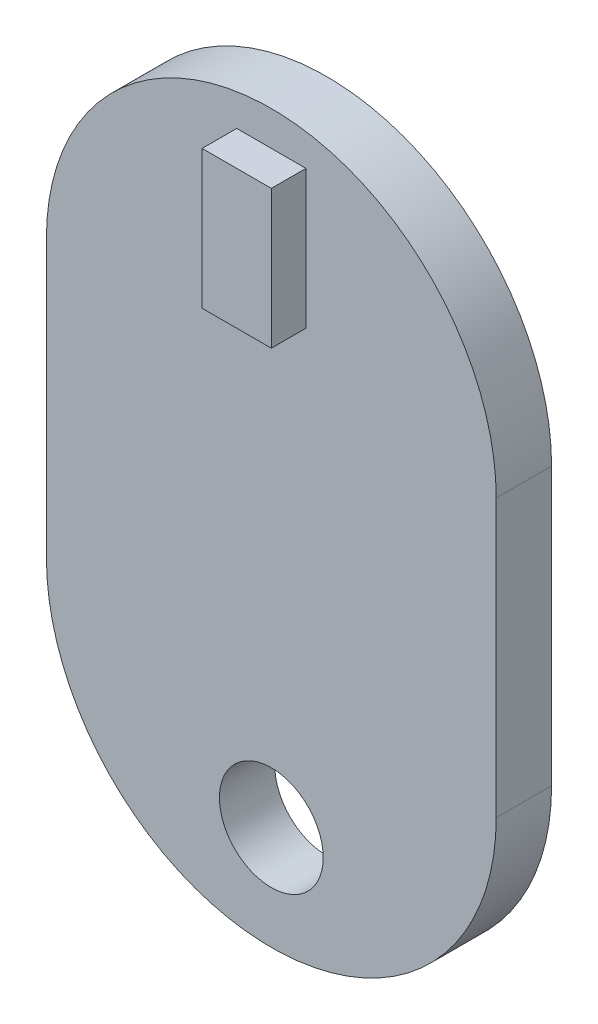
from build123d import *

# Parameters (mm, degrees)
ESQUISSE1_R        = 1.5
BOSS_EXTRU_1_DEPTH = 1.6
ESQUISSE2_W        = 2
ESQUISSE2_H        = 4
BOSS_EXTRU_2_DEPTH = 1


with BuildPart() as part:
    # Esquisse1 → Boss.-Extru.1 (new body)
    with BuildSketch(Plane.XY):
        with BuildLine():
            Line((6.5, -3.5), (6.5, -11.5))
            ThreePointArc((6.5, -11.5), (0, -18), (-6.5, -11.5))
            Line((-6.5, -11.5), (-6.5, -3.5))
            ThreePointArc((-6.5, -3.5), (0, 3), (6.5, -3.5))
        make_face()
        with Locations((0, -15)):
            Circle(ESQUISSE1_R, mode=Mode.SUBTRACT)
    extrude(amount=BOSS_EXTRU_1_DEPTH)

    # Esquisse2 → Boss.-Extru.2 (add)
    with BuildSketch(Plane.XY.offset(1.6)):
        Rectangle(ESQUISSE2_W, ESQUISSE2_H)
    extrude(amount=BOSS_EXTRU_2_DEPTH)


solid = part.part
